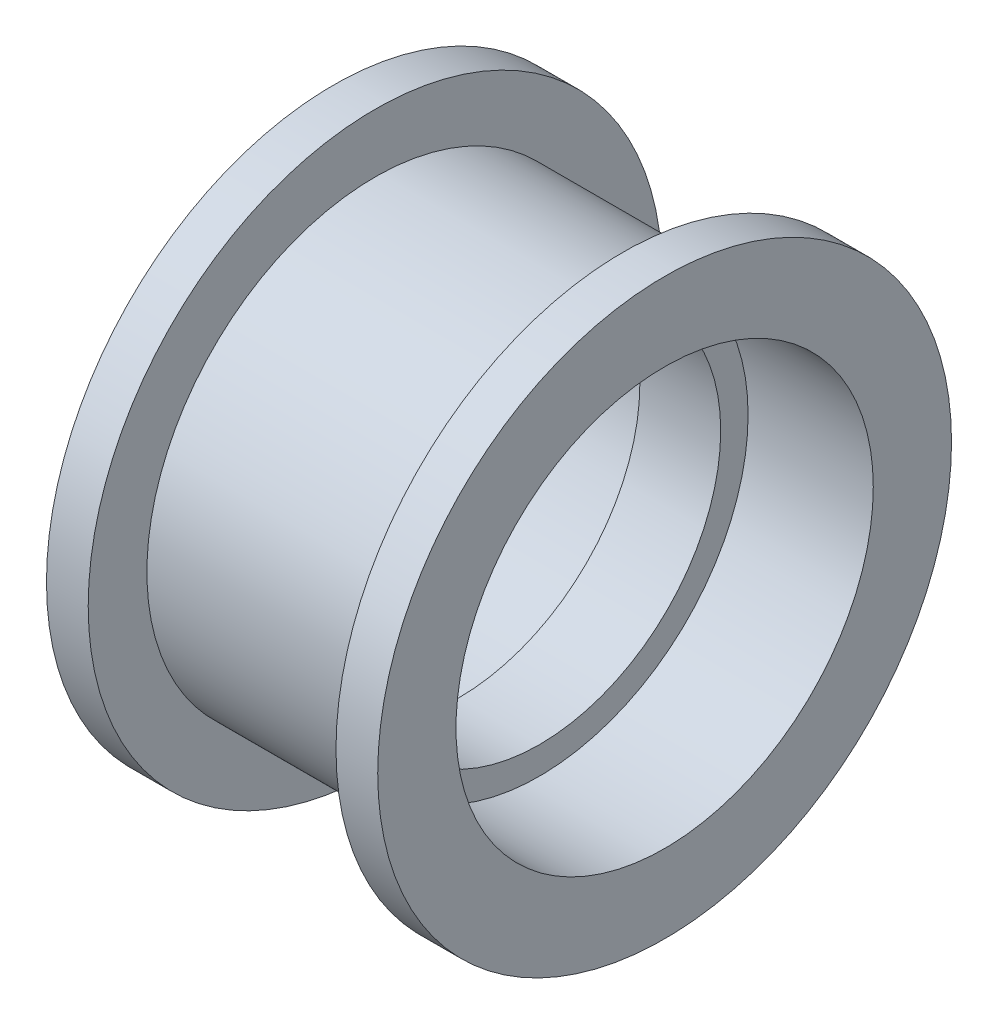
from build123d import *


with BuildPart() as part:
    # Sketch1 → Revolve1 (revolve)
    with BuildSketch(Plane.XY):
        Polygon((1.55, 6.95), (-1.55, 6.95), (-1.55, 8), (-6.35, 8), (-6.35, 11), (-4.75, 11), (-4.75, 8.75), (4.75, 8.75), (4.75, 11), (6.35, 11), (6.35, 8), (1.55, 8), align=None)
    revolve(axis=Axis((0, 0, 0), (-1, 0, 0)))


solid = part.part
